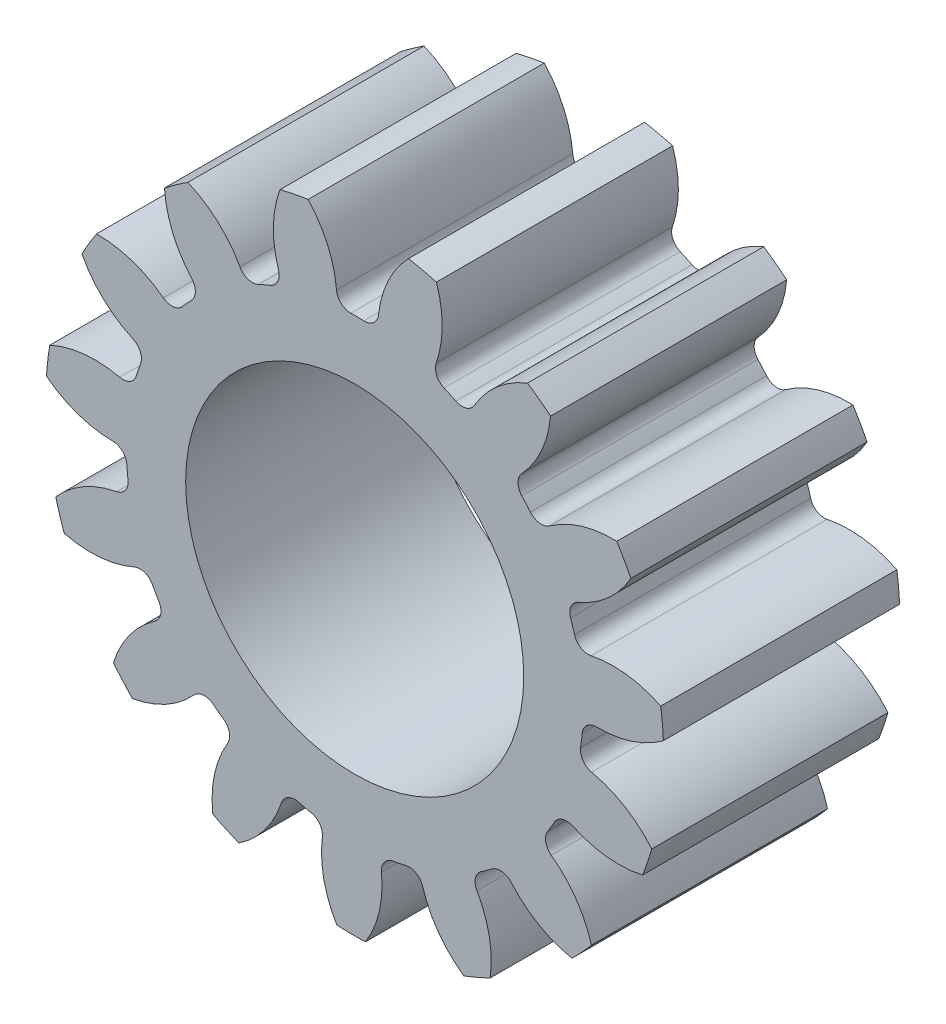
from build123d import *

# Parameters (mm, degrees)
SKETCH3_R         = 21.59
GEARBODY_DEPTH    = 11
TOOTHCUT_DEPTH    = 12
CIRPATTERN1_COUNT = 15
SCALE1_SCALE_X    = 0.666666667
SCALE1_SCALE_Y    = 0.666666667
SCALE1_SCALE_Z    = 1
BOREDIA_R         = 7.874
BORE_DEPTH        = 12700


with BuildPart() as part:
    # Sketch3 → gearBody (new body)
    with BuildSketch(Plane.XY):
        Circle(SKETCH3_R)
    extrude(amount=GEARBODY_DEPTH)

    # Sketch2 → toothCut (cut, through all)
    with BuildSketch(Plane.XY):
        with BuildLine():
            ThreePointArc((16.550574786, -3.410158156), (15.949189176, -3.008551507), (15.783846764, -2.304552616))
            ThreePointArc((15.783846764, -2.304552616), (15.843293638, -1.852249483), (15.889781974, -1.39843136))
            ThreePointArc((15.889781974, -1.39843136), (16.213055843, -0.751556907), (16.890861518, -0.499501321))
            ThreePointArc((16.890861518, -0.499501321), (20.504912911, 0.340315353), (23.283949955, 2.798691365))
            ThreePointArc((23.283949955, 2.798691365), (23.292901215, -2.723187818), (22.010467945, -8.09409042))
            ThreePointArc((22.010467945, -8.09409042), (19.873444675, -5.060974685), (16.550574786, -3.410158156))
        make_face()
    toothcut = extrude(amount=TOOTHCUT_DEPTH, mode=Mode.SUBTRACT)

    # CirPattern1: toothCut ×15 about axis
    cirpattern1_axis = Axis((0, 0, 0), (0, 0, 1))
    for i in range(1, CIRPATTERN1_COUNT):
        add(toothcut.rotate(cirpattern1_axis, i * 360 / CIRPATTERN1_COUNT), mode=Mode.SUBTRACT)


with BuildPart() as part_1:
    # Scale1: scaled about (0, 0, 5.5)
    add(part.part.scale((SCALE1_SCALE_X, SCALE1_SCALE_Y, SCALE1_SCALE_Z), about=(0, 0, 5.5)))

    # boreDia → bore (cut, symmetric)
    with BuildSketch(Plane.XY):
        Circle(BOREDIA_R)
    extrude(amount=BORE_DEPTH, both=True, mode=Mode.SUBTRACT)


solid = part_1.part
